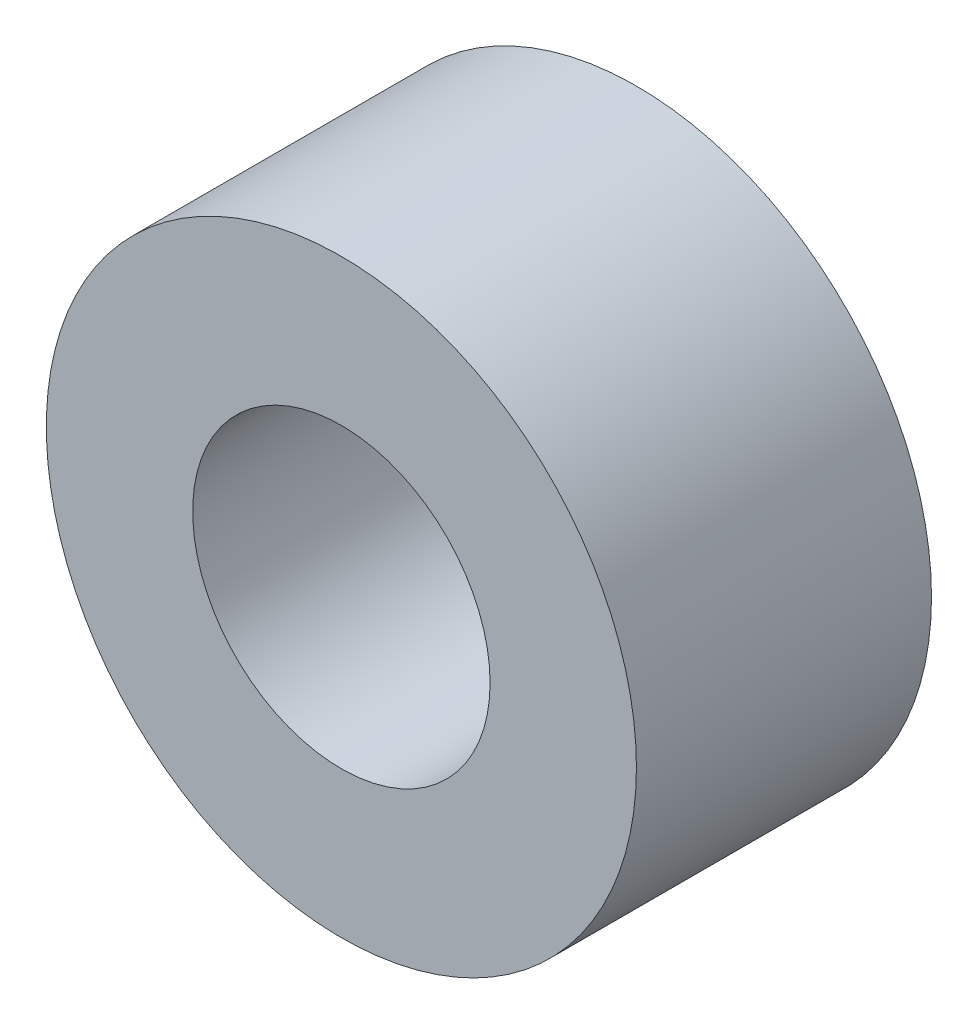
from build123d import *

# Parameters (mm, degrees)
SKETCH1_R           = 6.35
SKETCH1_R_2         = 3.2004
EXTRUDE1_DEPTH      = 3.175
EXTRUDE1_DEPTH_BACK = 3.175


with BuildPart() as part:
    # Sketch1 → Extrude1 (new body, two sides)
    with BuildSketch(Plane.XY) as extrude1_sk:
        Circle(SKETCH1_R)
        Circle(SKETCH1_R_2, mode=Mode.SUBTRACT)
    extrude(amount=EXTRUDE1_DEPTH)
    extrude(extrude1_sk.sketch, amount=-EXTRUDE1_DEPTH_BACK)


solid = part.part
